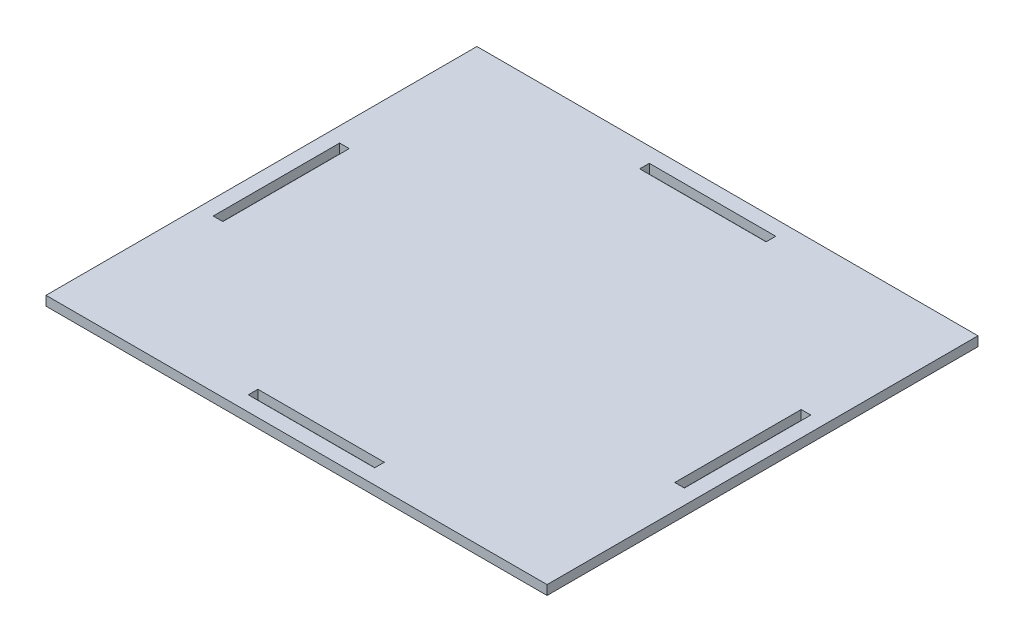
from build123d import *

# Parameters (mm, degrees)
SKETCH1_W           = 158.75
SKETCH1_H           = 136.525
BOSS_EXTRUDE1_DEPTH = 1.4986
SKETCH2_W           = 40.0508
SKETCH2_H           = 3.048
SKETCH2_W_2         = 3.048
SKETCH2_H_2         = 40.0508
CUT_EXTRUDE1_DEPTH  = 3.9972


with BuildPart() as part:
    # Sketch1 → Boss-Extrude1 (new body, symmetric)
    with BuildSketch(Plane(origin=(0, 0, 0), x_dir=(1, 0, 0), z_dir=(0, 1, 0))):
        Rectangle(SKETCH1_W, SKETCH1_H)
    extrude(amount=BOSS_EXTRUDE1_DEPTH, both=True)

    # Sketch2 → Cut-Extrude1 (cut, through all)
    with BuildSketch(Plane(origin=(0, 1.4986, 0), x_dir=(1, 0, 0), z_dir=(0, 1, 0))):
        with Locations((0, 62.0014)):
            Rectangle(SKETCH2_W, SKETCH2_H)
        with Locations((-73.1139, 0)):
            Rectangle(SKETCH2_W_2, SKETCH2_H_2)
        with Locations((0, -62.0014)):
            Rectangle(SKETCH2_W, SKETCH2_H)
        with Locations((73.1139, 0)):
            Rectangle(SKETCH2_W_2, SKETCH2_H_2)
    extrude(amount=-CUT_EXTRUDE1_DEPTH, mode=Mode.SUBTRACT)


solid = part.part
